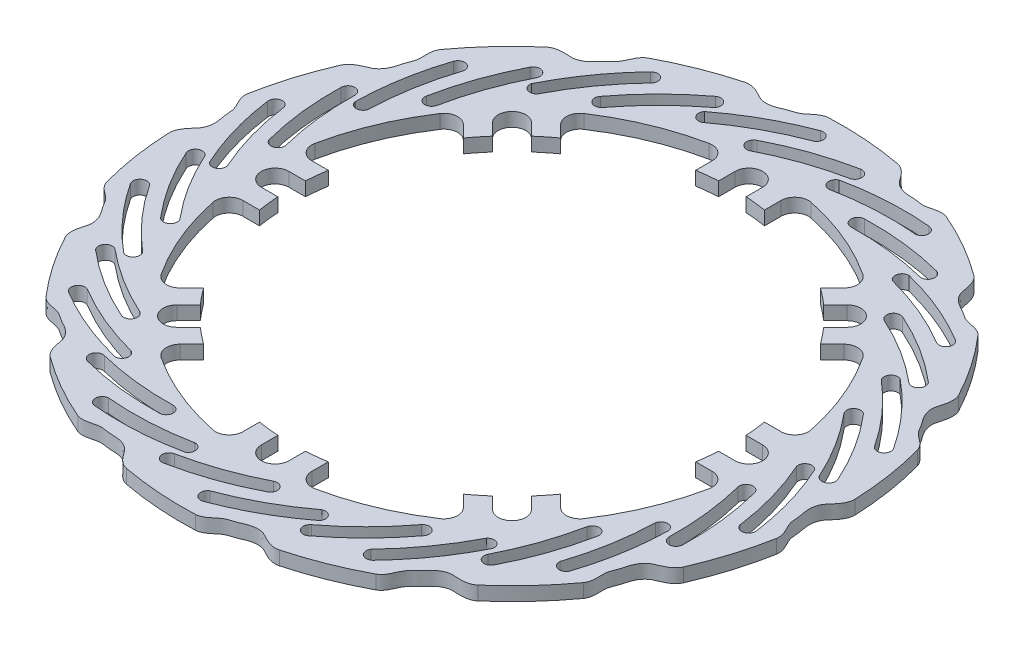
from build123d import *

# Parameters (mm, degrees)
DODANIE_WYCI_GNI_CIE1_DEPTH = 5


with BuildPart() as part:
    # Szkic1 → Dodanie-wyciągnięcie1 (new body)
    with BuildSketch(Plane.XZ):
        with BuildLine():
            ThreePointArc((31.315332852, 115.841917838), (44.179213836, 111.571488584), (56.479453956, 105.87762408))
            add(Edge.make_bspline(
                [(56.479453956, 105.87762408), (57.7973549, 105.079372549), (59.197175801, 102.852685767), (60.48538659, 99.334780786), (63.365232157, 97.088946445), (65.548394796, 94.026582105), (69.380131301, 91.841814605), (73.854427475, 92.533279482), (77.134407867, 91.946217157), (78.476064445, 90.782747861)],
                knots=[0, 0, 0, 0, 0.147553596, 0.283238405, 0.382647471, 0.524820265, 0.68196142, 0.812365732, 1, 1, 1, 1], degree=3))
            ThreePointArc((78.476064445, 90.782747861), (88.21315092, 81.353795269), (96.824809115, 70.886926438))
            add(Edge.make_bspline(
                [(96.824809115, 70.886926438), (97.665848478, 69.595910871), (97.960920344, 66.982375875), (97.595196392, 63.253919293), (99.215416591, 59.980974306), (99.853668074, 56.274640605), (102.358008279, 52.64370494), (106.689225217, 51.325368919), (109.389668596, 49.373313865), (110.09364903, 47.742941293)],
                knots=[0, 0, 0, 0, 0.147553596, 0.283238405, 0.382647471, 0.524820265, 0.68196142, 0.812365732, 1, 1, 1, 1], degree=3))
            ThreePointArc((110.09364903, 47.742941293), (114.775391602, 35.022985063), (117.992823351, 21.856203644))
            add(Edge.make_bspline(
                [(117.992823351, 21.856203644), (118.190422971, 20.328125506), (117.3223032, 17.845384955), (115.375080623, 14.644843325), (115.414770972, 10.993034587), (114.381697764, 7.376816369), (115.062626377, 3.018863882), (118.392913452, -0.048160431), (119.978963868, -2.978579732), (119.905836215, -4.752940328)],
                knots=[0, 0, 0, 0, 0.147553596, 0.283238405, 0.382647471, 0.524820265, 0.68196142, 0.812365732, 1, 1, 1, 1], degree=3))
            ThreePointArc((119.905836215, -4.752940328), (118.604958349, -18.244556864), (115.790911836, -31.503408331))
            add(Edge.make_bspline(
                [(115.790911836, -31.503408331), (115.305934686, -32.965894423), (113.446565044, -34.826103314), (110.303515154, -36.86482347), (108.754814493, -40.172210452), (106.255029413, -42.98207682), (104.977680171, -47.20390019), (106.647433182, -51.412151028), (106.804953908, -54.740529052), (105.969201989, -56.307443825)],
                knots=[0, 0, 0, 0, 0.147553596, 0.283238405, 0.382647471, 0.524820265, 0.68196142, 0.812365732, 1, 1, 1, 1], degree=3))
            ThreePointArc((105.969201989, -56.307443825), (98.943358501, -67.89854055), (90.655190149, -78.623383922))
            add(Edge.make_bspline(
                [(90.655190149, -78.623383922), (89.583691901, -79.730614661), (87.101343351, -80.599854708), (83.384985725, -81.07295986), (80.554633213, -83.380856531), (77.083249354, -84.827842555), (74.100616942, -88.077352909), (73.779120818, -92.593334589), (72.47691297, -95.660445229), (71.044067681, -96.709567508)],
                knots=[0, 0, 0, 0, 0.147553596, 0.283238405, 0.382647471, 0.524820265, 0.68196142, 0.812365732, 1, 1, 1, 1], degree=3))
            ThreePointArc((71.044067681, -96.709567508), (59.684813041, -104.104385559), (47.564096239, -110.171034075))
            add(Edge.make_bspline(
                [(47.564096239, -110.171034075), (46.118300263, -110.703708834), (43.504632379, -110.409816384), (39.951037223, -109.223602255), (36.399618888, -110.074901376), (32.644186396, -109.872413726), (28.547017745, -111.506005688), (26.29794873, -115.435272651), (23.793930565, -117.633637036), (22.047784471, -117.957175281)],
                knots=[0, 0, 0, 0, 0.147553596, 0.283238405, 0.382647471, 0.524820265, 0.68196142, 0.812365732, 1, 1, 1, 1], degree=3))
            ThreePointArc((22.047784471, -117.957175281), (8.604958371, -119.691080251), (-4.947650265, -119.897959771))
            add(Edge.make_bspline(
                [(-4.947650265, -119.897959771), (-6.481386346, -119.750575781), (-8.708704585, -118.351759838), (-11.395704168, -115.741170684), (-14.96478637, -114.967262022), (-18.260458033, -113.155405862), (-22.660668422, -112.84952651), (-26.391854628, -115.413839238), (-29.601731603, -116.308044362), (-31.315332852, -115.841917839)],
                knots=[0, 0, 0, 0, 0.147553596, 0.283238405, 0.382647471, 0.524820265, 0.68196142, 0.812365732, 1, 1, 1, 1], degree=3))
            ThreePointArc((-31.315332852, -115.841917839), (-44.179213836, -111.571488585), (-56.479453956, -105.877624081))
            add(Edge.make_bspline(
                [(-56.479453956, -105.877624081), (-57.7973549, -105.07937255), (-59.197175801, -102.852685768), (-60.48538659, -99.334780786), (-63.365232157, -97.088946445), (-65.548394798, -94.026582107), (-69.380131296, -91.841814599), (-73.854427495, -92.533279504), (-77.134407806, -91.946217086), (-78.476064446, -90.782747861)],
                knots=[0, 0, 0, 0, 0.147553596, 0.283238405, 0.382647471, 0.524820265, 0.68196142, 0.812365732, 1, 1, 1, 1], degree=3))
            ThreePointArc((-78.476064446, -90.782747861), (-88.213150921, -81.35379527), (-96.824809116, -70.886926439))
            add(Edge.make_bspline(
                [(-96.824809116, -70.886926439), (-97.665848477, -69.595910871), (-97.960920344, -66.982375875), (-97.595196392, -63.253919293), (-99.215416591, -59.980974306), (-99.853668074, -56.274640605), (-102.358008277, -52.64370494), (-106.689225223, -51.325368922), (-109.389668578, -49.373313857), (-110.093649031, -47.742941293)],
                knots=[0, 0, 0, 0, 0.147553596, 0.283238405, 0.382647471, 0.524820265, 0.68196142, 0.812365732, 1, 1, 1, 1], degree=3))
            ThreePointArc((-110.093649031, -47.742941293), (-114.775391602, -35.022985063), (-117.992823351, -21.856203644))
            add(Edge.make_bspline(
                [(-117.992823351, -21.856203644), (-118.190422971, -20.328125506), (-117.3223032, -17.845384955), (-115.375080623, -14.644843325), (-115.414770973, -10.993034587), (-114.381697763, -7.376816369), (-115.062626382, -3.018863882), (-118.392913433, 0.048160431), (-119.978963928, 2.978579735), (-119.905836214, 4.752940328)],
                knots=[0, 0, 0, 0, 0.147553596, 0.283238405, 0.382647471, 0.524820265, 0.68196142, 0.812365732, 1, 1, 1, 1], degree=3))
            ThreePointArc((-119.905836214, 4.752940328), (-118.604958349, 18.244556864), (-115.790911835, 31.503408331))
            add(Edge.make_bspline(
                [(-115.790911835, 31.503408331), (-115.305934685, 32.965894423), (-113.446565044, 34.826103314), (-110.303515154, 36.86482347), (-108.754814494, 40.172210452), (-106.255029411, 42.982076819), (-104.977680181, 47.203900195), (-106.647433147, 51.412151009), (-106.804954019, 54.740529112), (-105.969201988, 56.307443825)],
                knots=[0, 0, 0, 0, 0.147553596, 0.283238405, 0.382647471, 0.524820265, 0.68196142, 0.812365732, 1, 1, 1, 1], degree=3))
            ThreePointArc((-105.969201988, 56.307443825), (-98.9433585, 67.898540549), (-90.655190148, 78.623383921))
            add(Edge.make_bspline(
                [(-90.655190148, 78.623383921), (-89.5836919, 79.730614661), (-87.101343351, 80.599854708), (-83.384985724, 81.07295986), (-80.554633214, 83.380856532), (-77.083249352, 84.827842552), (-74.100616951, 88.077352921), (-73.779120787, 92.593334547), (-72.476913069, 95.660445365), (-71.04406768, 96.709567507)],
                knots=[0, 0, 0, 0, 0.147553596, 0.283238405, 0.382647471, 0.524820265, 0.68196142, 0.812365732, 1, 1, 1, 1], degree=3))
            ThreePointArc((-71.04406768, 96.709567507), (-59.68481304, 104.104385558), (-47.564096239, 110.171034074))
            add(Edge.make_bspline(
                [(-47.564096239, 110.171034074), (-46.118300263, 110.703708834), (-43.504632378, 110.409816384), (-39.951037223, 109.223602255), (-36.399618888, 110.074901376), (-32.644186395, 109.872413723), (-28.547017748, 111.5060057), (-26.297948722, 115.435272608), (-23.79393059, 117.633637172), (-22.047784471, 117.957175279)],
                knots=[0, 0, 0, 0, 0.147553596, 0.283238405, 0.382647471, 0.524820265, 0.68196142, 0.812365732, 1, 1, 1, 1], degree=3))
            ThreePointArc((-22.047784471, 117.957175279), (-8.604958371, 119.69108025), (4.947650265, 119.897959769))
            add(Edge.make_bspline(
                [(4.947650265, 119.897959769), (6.481386346, 119.750575781), (8.708704586, 118.351759838), (11.395704168, 115.741170684), (14.964786371, 114.967262023), (18.260458032, 113.155405859), (22.660668426, 112.849526523), (26.391854615, 115.413839193), (29.601731642, 116.308044507), (31.315332852, 115.841917838)],
                knots=[0, 0, 0, 0, 0.147553596, 0.283238405, 0.382647471, 0.524820265, 0.68196142, 0.812365732, 1, 1, 1, 1], degree=3))
        make_face()
        with BuildLine():
            Line((-79.219883867, 12.499999999), (-85.221769519, 12.499999999))
            ThreePointArc((-85.221769519, 12.499999999), (-89.096607298, 14.339994907), (-90.119572365, 18.505747126))
            ThreePointArc((-90.119572365, 18.505747126), (-84.996916991, 35.206875777), (-76.809700021, 50.638621452))
            ThreePointArc((-76.809700021, 50.638621452), (-73.140722843, 52.860907559), (-69.099725896, 51.422056366))
            Line((-69.099725896, 51.422056366), (-64.855751852, 47.178082322))
            ThreePointArc((-64.855751852, 47.178082322), (-62.564723559, 50.176641636), (-60.135180548, 53.064112735))
            Line((-60.135180548, 53.064112735), (-64.377821235, 57.306753422))
            ThreePointArc((-64.377821235, 57.306753422), (-64.377821235, 64.377821234), (-57.306753423, 64.377821234))
            Line((-57.306753423, 64.377821234), (-53.064112736, 60.135180547))
            ThreePointArc((-53.064112736, 60.135180547), (-50.176641636, 62.564723559), (-47.178082323, 64.855751852))
            Line((-47.178082323, 64.855751852), (-51.422056367, 69.099725896))
            ThreePointArc((-51.422056367, 69.099725896), (-52.86090756, 73.140722842), (-50.638621453, 76.80970002))
            ThreePointArc((-50.638621453, 76.80970002), (-35.206875777, 84.99691699), (-18.505747126, 90.119572364))
            ThreePointArc((-18.505747126, 90.119572364), (-14.339994907, 89.096607298), (-12.5, 85.221769519))
            Line((-12.5, 85.221769519), (-12.5, 79.219883867))
            ThreePointArc((-12.5, 79.219883867), (-8.759696733, 79.72018385), (-5, 80.043987906))
            Line((-5, 80.043987906), (-5, 86.043987906))
            ThreePointArc((-5, 86.043987906), (0, 91.043987906), (5, 86.043987906))
            Line((5, 86.043987906), (5, 80.043987906))
            ThreePointArc((5, 80.043987906), (8.759696734, 79.72018385), (12.5, 79.219883867))
            Line((12.5, 79.219883867), (12.5, 85.221769519))
            ThreePointArc((12.5, 85.221769519), (14.339994908, 89.096607298), (18.505747127, 90.119572364))
            ThreePointArc((18.505747127, 90.119572364), (35.206875778, 84.99691699), (50.638621453, 76.80970002))
            ThreePointArc((50.638621453, 76.80970002), (52.86090756, 73.140722842), (51.422056367, 69.099725896))
            Line((51.422056367, 69.099725896), (47.178082323, 64.855751852))
            ThreePointArc((47.178082323, 64.855751852), (50.176641637, 62.564723559), (53.064112736, 60.135180547))
            Line((53.064112736, 60.135180547), (57.306753423, 64.377821234))
            ThreePointArc((57.306753423, 64.377821234), (64.377821235, 64.377821234), (64.377821235, 57.306753422))
            Line((64.377821235, 57.306753422), (60.135180548, 53.064112735))
            ThreePointArc((60.135180548, 53.064112735), (62.56472356, 50.176641636), (64.855751853, 47.178082322))
            Line((64.855751853, 47.178082322), (69.099725897, 51.422056366))
            ThreePointArc((69.099725897, 51.422056366), (73.140722843, 52.860907559), (76.809700021, 50.638621452))
            ThreePointArc((76.809700021, 50.638621452), (84.996916991, 35.206875777), (90.119572365, 18.505747126))
            ThreePointArc((90.119572365, 18.505747126), (89.096607299, 14.339994907), (85.22176952, 12.499999999))
            Line((85.22176952, 12.499999999), (79.219883868, 12.499999999))
            ThreePointArc((79.219883868, 12.499999999), (79.720183851, 8.759696733), (80.043987907, 4.999999999))
            Line((80.043987907, 4.999999999), (86.043987907, 4.999999999))
            ThreePointArc((86.043987907, 4.999999999), (91.043987907, -1e-09), (86.043987907, -5.000000001))
            Line((86.043987907, -5.000000001), (80.043987907, -5.000000001))
            ThreePointArc((80.043987907, -5.000000001), (79.720183851, -8.759696734), (79.219883868, -12.500000001))
            Line((79.219883868, -12.500000001), (85.22176952, -12.500000001))
            ThreePointArc((85.22176952, -12.500000001), (89.096607299, -14.339994908), (90.119572365, -18.505747127))
            ThreePointArc((90.119572365, -18.505747127), (84.996916991, -35.206875778), (76.809700021, -50.638621454))
            ThreePointArc((76.809700021, -50.638621454), (73.140722843, -52.860907561), (69.099725897, -51.422056368))
            Line((69.099725897, -51.422056368), (64.855751853, -47.178082324))
            ThreePointArc((64.855751853, -47.178082324), (62.56472356, -50.176641637), (60.135180548, -53.064112737))
            Line((60.135180548, -53.064112737), (64.377821235, -57.306753424))
            ThreePointArc((64.377821235, -57.306753424), (64.377821235, -64.377821236), (57.306753423, -64.377821236))
            Line((57.306753423, -64.377821236), (53.064112736, -60.135180549))
            ThreePointArc((53.064112736, -60.135180549), (50.176641637, -62.56472356), (47.178082323, -64.855751853))
            Line((47.178082323, -64.855751853), (51.422056367, -69.099725897))
            ThreePointArc((51.422056367, -69.099725897), (52.86090756, -73.140722844), (50.638621453, -76.809700022))
            ThreePointArc((50.638621453, -76.809700022), (35.206875778, -84.996916992), (18.505747127, -90.119572366))
            ThreePointArc((18.505747127, -90.119572366), (14.339994908, -89.096607299), (12.5, -85.22176952))
            Line((12.5, -85.22176952), (12.5, -79.219883868))
            ThreePointArc((12.5, -79.219883868), (8.759696734, -79.720183851), (5, -80.043987907))
            Line((5, -80.043987907), (5, -86.043987907))
            ThreePointArc((5, -86.043987907), (0, -91.043987907), (-5, -86.043987907))
            Line((-5, -86.043987907), (-5, -80.043987907))
            ThreePointArc((-5, -80.043987907), (-8.759696733, -79.720183851), (-12.5, -79.219883868))
            Line((-12.5, -79.219883868), (-12.5, -85.22176952))
            ThreePointArc((-12.5, -85.22176952), (-14.339994907, -89.096607299), (-18.505747126, -90.119572366))
            ThreePointArc((-18.505747126, -90.119572366), (-35.206875777, -84.996916992), (-50.638621453, -76.809700022))
            ThreePointArc((-50.638621453, -76.809700022), (-52.86090756, -73.140722844), (-51.422056367, -69.099725897))
            Line((-51.422056367, -69.099725897), (-47.178082323, -64.855751853))
            ThreePointArc((-47.178082323, -64.855751853), (-50.176641636, -62.56472356), (-53.064112736, -60.135180549))
            Line((-53.064112736, -60.135180549), (-57.306753423, -64.377821236))
            ThreePointArc((-57.306753423, -64.377821236), (-64.377821235, -64.377821236), (-64.377821235, -57.306753424))
            Line((-64.377821235, -57.306753424), (-60.135180548, -53.064112737))
            ThreePointArc((-60.135180548, -53.064112737), (-62.564723559, -50.176641637), (-64.855751852, -47.178082324))
            Line((-64.855751852, -47.178082324), (-69.099725896, -51.422056368))
            ThreePointArc((-69.099725896, -51.422056368), (-73.140722843, -52.860907561), (-76.809700021, -50.638621454))
            ThreePointArc((-76.809700021, -50.638621454), (-84.996916991, -35.206875778), (-90.119572365, -18.505747127))
            ThreePointArc((-90.119572365, -18.505747127), (-89.096607298, -14.339994908), (-85.221769519, -12.500000001))
            Line((-85.221769519, -12.500000001), (-79.219883867, -12.500000001))
            ThreePointArc((-79.219883867, -12.500000001), (-79.72018385, -8.759696734), (-80.043987906, -5.000000001))
            Line((-80.043987906, -5.000000001), (-86.043987906, -5.000000001))
            ThreePointArc((-86.043987906, -5.000000001), (-91.043987906, -1e-09), (-86.043987906, 4.999999999))
            Line((-86.043987906, 4.999999999), (-80.043987906, 4.999999999))
            ThreePointArc((-80.043987906, 4.999999999), (-79.72018385, 8.759696733), (-79.219883867, 12.499999999))
        make_face(mode=Mode.SUBTRACT)
        with BuildLine():
            ThreePointArc((2.268312667, 114.334257918), (16.405394511, 107.826943281), (29.410258709, 99.278508685))
            ThreePointArc((29.410258709, 99.278508685), (29.416149704, 96.178074413), (26.400917875, 95.456198803))
            ThreePointArc((26.400917875, 95.456198803), (13.759854388, 103.608740692), (0.080835869, 109.865327437))
            ThreePointArc((0.080835869, 109.865327437), (-0.849204784, 113.090403236), (2.268312667, 114.334257918))
        make_face(mode=Mode.SUBTRACT)
        with BuildLine():
            ThreePointArc((-17.021818385, 109.530618868), (-2.743365473, 105.63635259), (10.842358325, 99.765438156))
            ThreePointArc((10.842358325, 99.765438156), (12.010071147, 96.428306638), (8.67293963, 95.260593816))
            ThreePointArc((8.67293963, 95.260593816), (-4.35084411, 100.849193335), (-18.00964822, 104.629200974))
            ThreePointArc((-18.00964822, 104.629200974), (-19.958040423, 107.572131537), (-17.021818385, 109.530618868))
        make_face(mode=Mode.SUBTRACT)
        with BuildLine():
            ThreePointArc((51.651454431, 102.027422937), (61.565107048, 90.030685105), (69.573058056, 76.68621256))
            ThreePointArc((69.573058056, 76.68621256), (68.233137644, 73.890261797), (65.203297548, 74.548134406))
            ThreePointArc((65.203297548, 74.548134406), (57.351348247, 87.378072735), (47.741609669, 98.950166313))
            ThreePointArc((47.741609669, 98.950166313), (48.302979942, 102.259388721), (51.651454431, 102.027422937))
        make_face(mode=Mode.SUBTRACT)
        with BuildLine():
            ThreePointArc((32.187426022, 106.06916789), (43.362208764, 96.365366671), (53.055228647, 85.1812309))
            ThreePointArc((53.055228647, 85.1812309), (52.659374446, 81.667927689), (49.146071235, 82.063781891))
            ThreePointArc((49.146071235, 82.063781891), (39.836849999, 92.749744058), (29.170776571, 102.081746261))
            ThreePointArc((29.170776571, 102.081746261), (28.692225571, 105.578610773), (32.187426022, 106.06916789))
        make_face(mode=Mode.SUBTRACT)
        with BuildLine():
            ThreePointArc((90.80439218, 69.51280556), (94.531095088, 54.40274559), (95.956059997, 38.905271543))
            ThreePointArc((95.956059997, 38.905271543), (93.535715849, 36.967576627), (91.091364475, 38.874897717))
            ThreePointArc((91.091364475, 38.874897717), (89.583704218, 53.84110585), (85.946572162, 68.436711207))
            ThreePointArc((85.946572162, 68.436711207), (87.888167093, 71.174648141), (90.80439218, 69.51280556))
        make_face(mode=Mode.SUBTRACT)
        with BuildLine():
            ThreePointArc((75.021555953, 81.599417358), (80.879365753, 68.00803804), (84.759860256, 53.725836185))
            ThreePointArc((84.759860256, 53.725836185), (82.878842811, 50.73221407), (79.885220695, 52.613231515))
            ThreePointArc((79.885220695, 52.613231515), (76.134367399, 66.28007047), (70.573571307, 79.31574975))
            ThreePointArc((70.573571307, 79.31574975), (71.659644404, 82.673951309), (75.021555953, 81.599417358))
        make_face(mode=Mode.SUBTRACT)
        with BuildLine():
            ThreePointArc((111.972406416, 23.230324522), (108.774040398, 7.999675105), (103.333787432, -6.581335645))
            ThreePointArc((103.333787432, -6.581335645), (100.31239839, -7.276990471), (98.937669506, -4.497989234))
            ThreePointArc((98.937669506, -4.497989234), (104.072908896, 9.640247635), (107.128761972, 24.368526126))
            ThreePointArc((107.128761972, 24.368526126), (110.066024873, 25.992895596), (111.972406416, 23.230324522))
        make_face(mode=Mode.SUBTRACT)
        with BuildLine():
            ThreePointArc((102.996746648, 40.967901467), (102.377372434, 26.180883411), (99.67676203, 11.62938071))
            ThreePointArc((99.67676203, 11.62938071), (96.683139914, 9.748363264), (94.802122469, 12.74198538))
            ThreePointArc((94.802122469, 12.74198538), (97.352539608, 26.682816054), (97.998404717, 40.840296258))
            ThreePointArc((97.998404717, 40.840296258), (100.433991814, 43.394701858), (102.996746648, 40.967901467))
        make_face(mode=Mode.SUBTRACT)
        with BuildLine():
            ThreePointArc((110.96291231, -27.653207188), (101.472952981, -39.987829144), (90.244990961, -50.764428594))
            ThreePointArc((90.244990961, -50.764428594), (87.220980179, -50.080260359), (87.188155701, -46.979994253))
            ThreePointArc((87.188155701, -46.979994253), (97.949197597, -36.469979855), (107.092786626, -24.526144415))
            ThreePointArc((107.092786626, -24.526144415), (110.443956556, -24.337068703), (110.96291231, -27.653207188))
        make_face(mode=Mode.SUBTRACT)
        with BuildLine():
            ThreePointArc((110.572168498, -7.777809748), (103.598284928, -20.831716265), (94.851458628, -32.77041624))
            ThreePointArc((94.851458628, -32.77041624), (91.338155417, -33.166270442), (90.942301216, -29.652967231))
            ThreePointArc((90.942301216, -29.652967231), (99.288847398, -18.199297325), (106.013452201, -5.724078782))
            ThreePointArc((106.013452201, -5.724078782), (109.316155404, -4.479400497), (110.572168498, -7.777809748))
        make_face(mode=Mode.SUBTRACT)
        with BuildLine():
            ThreePointArc((87.97585255, -73.05968207), (74.073902742, -80.055253412), (59.282067247, -84.893003875))
            ThreePointArc((59.282067247, -84.893003875), (56.854377149, -82.96452049), (58.169958366, -80.157035238))
            ThreePointArc((58.169958366, -80.157035238), (72.425446446, -75.35688056), (85.845771482, -68.563111262))
            ThreePointArc((85.845771482, -68.563111262), (88.947108137, -69.846778071), (87.97585255, -73.05968207))
        make_face(mode=Mode.SUBTRACT)
        with BuildLine():
            ThreePointArc((96.247416297, -54.983030353), (84.300286543, -63.718339051), (71.239660568, -70.679630351))
            ThreePointArc((71.239660568, -70.679630351), (67.902529051, -69.511917529), (69.070241873, -66.174786011))
            ThreePointArc((69.070241873, -66.174786011), (81.559781263, -59.47681667), (93.031235307, -51.154729817))
            ThreePointArc((93.031235307, -51.154729817), (96.546913741, -51.466302647), (96.247416297, -54.983030353))
        make_face(mode=Mode.SUBTRACT)
        with BuildLine():
            ThreePointArc((47.564096239, -103.9957909), (32.003607608, -104.266752929), (16.577603069, -102.207478594))
            ThreePointArc((16.577603069, -102.207478594), (15.227067451, -99.416639845), (17.630487369, -97.457992333))
            ThreePointArc((17.630487369, -97.457992333), (32.556947386, -99.318426878), (47.595948466, -99.020313051))
            ThreePointArc((47.595948466, -99.020313051), (49.833194087, -101.522476427), (47.564096239, -103.9957909))
        make_face(mode=Mode.SUBTRACT)
        with BuildLine():
            ThreePointArc((62.859682902, -91.298187475), (48.305582533, -93.984763333), (33.517974036, -94.589876842))
            ThreePointArc((33.517974036, -94.589876842), (31.017974036, -92.089876842), (33.517974036, -89.589876842))
            ThreePointArc((33.517974036, -89.589876842), (47.676800183, -88.974223037), (61.623041307, -86.453559241))
            ThreePointArc((61.623041307, -86.453559241), (64.655371741, -88.259672365), (62.859682902, -91.298187475))
        make_face(mode=Mode.SUBTRACT)
        with BuildLine():
            ThreePointArc((-2.268312667, -114.334257918), (-16.405394511, -107.826943281), (-29.410258709, -99.278508685))
            ThreePointArc((-29.410258709, -99.278508685), (-29.416149704, -96.178074413), (-26.400917875, -95.456198803))
            ThreePointArc((-26.400917875, -95.456198803), (-13.759854388, -103.608740692), (-0.080835869, -109.865327437))
            ThreePointArc((-0.080835869, -109.865327437), (0.849204784, -113.090403236), (-2.268312667, -114.334257918))
        make_face(mode=Mode.SUBTRACT)
        with BuildLine():
            ThreePointArc((17.021818385, -109.530618868), (2.743365473, -105.63635259), (-10.842358325, -99.765438156))
            ThreePointArc((-10.842358325, -99.765438156), (-12.010071147, -96.428306638), (-8.67293963, -95.260593816))
            ThreePointArc((-8.67293963, -95.260593816), (4.35084411, -100.849193335), (18.00964822, -104.629200974))
            ThreePointArc((18.00964822, -104.629200974), (19.958040423, -107.572131537), (17.021818385, -109.530618868))
        make_face(mode=Mode.SUBTRACT)
        with BuildLine():
            ThreePointArc((-51.651454431, -102.027422937), (-61.565107048, -90.030685105), (-69.573058056, -76.68621256))
            ThreePointArc((-69.573058056, -76.68621256), (-68.233137644, -73.890261797), (-65.203297548, -74.548134406))
            ThreePointArc((-65.203297548, -74.548134406), (-57.351348247, -87.378072735), (-47.741609669, -98.950166313))
            ThreePointArc((-47.741609669, -98.950166313), (-48.302979942, -102.259388721), (-51.651454431, -102.027422937))
        make_face(mode=Mode.SUBTRACT)
        with BuildLine():
            ThreePointArc((-32.187426022, -106.06916789), (-43.362208764, -96.365366671), (-53.055228647, -85.1812309))
            ThreePointArc((-53.055228647, -85.1812309), (-52.659374446, -81.667927689), (-49.146071235, -82.063781891))
            ThreePointArc((-49.146071235, -82.063781891), (-39.836849999, -92.749744058), (-29.170776571, -102.081746261))
            ThreePointArc((-29.170776571, -102.081746261), (-28.692225571, -105.578610773), (-32.187426022, -106.06916789))
        make_face(mode=Mode.SUBTRACT)
        with BuildLine():
            ThreePointArc((-90.80439218, -69.51280556), (-94.531095088, -54.40274559), (-95.956059997, -38.905271543))
            ThreePointArc((-95.956059997, -38.905271543), (-93.535715849, -36.967576627), (-91.091364475, -38.874897717))
            ThreePointArc((-91.091364475, -38.874897717), (-89.583704218, -53.84110585), (-85.946572162, -68.436711207))
            ThreePointArc((-85.946572162, -68.436711207), (-87.888167093, -71.174648141), (-90.80439218, -69.51280556))
        make_face(mode=Mode.SUBTRACT)
        with BuildLine():
            ThreePointArc((-75.021555953, -81.599417358), (-80.879365753, -68.00803804), (-84.759860256, -53.725836185))
            ThreePointArc((-84.759860256, -53.725836185), (-82.878842811, -50.73221407), (-79.885220695, -52.613231515))
            ThreePointArc((-79.885220695, -52.613231515), (-76.134367399, -66.28007047), (-70.573571307, -79.31574975))
            ThreePointArc((-70.573571307, -79.31574975), (-71.659644404, -82.673951309), (-75.021555953, -81.599417358))
        make_face(mode=Mode.SUBTRACT)
        with BuildLine():
            ThreePointArc((-111.972406416, -23.230324522), (-108.774040398, -7.999675105), (-103.333787432, 6.581335645))
            ThreePointArc((-103.333787432, 6.581335645), (-100.31239839, 7.276990471), (-98.937669506, 4.497989234))
            ThreePointArc((-98.937669506, 4.497989234), (-104.072908896, -9.640247635), (-107.128761972, -24.368526126))
            ThreePointArc((-107.128761972, -24.368526126), (-110.066024873, -25.992895596), (-111.972406416, -23.230324522))
        make_face(mode=Mode.SUBTRACT)
        with BuildLine():
            ThreePointArc((-102.996746648, -40.967901467), (-102.377372434, -26.180883411), (-99.67676203, -11.62938071))
            ThreePointArc((-99.67676203, -11.62938071), (-96.683139914, -9.748363264), (-94.802122469, -12.74198538))
            ThreePointArc((-94.802122469, -12.74198538), (-97.352539608, -26.682816054), (-97.998404717, -40.840296258))
            ThreePointArc((-97.998404717, -40.840296258), (-100.433991814, -43.394701858), (-102.996746648, -40.967901467))
        make_face(mode=Mode.SUBTRACT)
        with BuildLine():
            ThreePointArc((-110.96291231, 27.653207188), (-101.472952981, 39.987829144), (-90.244990961, 50.764428594))
            ThreePointArc((-90.244990961, 50.764428594), (-87.220980179, 50.080260359), (-87.188155701, 46.979994253))
            ThreePointArc((-87.188155701, 46.979994253), (-97.949197597, 36.469979855), (-107.092786626, 24.526144415))
            ThreePointArc((-107.092786626, 24.526144415), (-110.443956556, 24.337068703), (-110.96291231, 27.653207188))
        make_face(mode=Mode.SUBTRACT)
        with BuildLine():
            ThreePointArc((-110.572168498, 7.777809748), (-103.598284928, 20.831716265), (-94.851458628, 32.77041624))
            ThreePointArc((-94.851458628, 32.77041624), (-91.338155417, 33.166270442), (-90.942301216, 29.652967231))
            ThreePointArc((-90.942301216, 29.652967231), (-99.288847398, 18.199297325), (-106.013452201, 5.724078782))
            ThreePointArc((-106.013452201, 5.724078782), (-109.316155404, 4.479400497), (-110.572168498, 7.777809748))
        make_face(mode=Mode.SUBTRACT)
        with BuildLine():
            ThreePointArc((-61.623041307, 86.453559241), (-64.655371741, 88.259672365), (-62.859682902, 91.298187475))
            ThreePointArc((-62.859682902, 91.298187475), (-48.305582533, 93.984763333), (-33.517974036, 94.589876842))
            ThreePointArc((-33.517974036, 94.589876842), (-31.017974036, 92.089876842), (-33.517974036, 89.589876842))
            ThreePointArc((-33.517974036, 89.589876842), (-47.676800183, 88.974223037), (-61.623041307, 86.453559241))
        make_face(mode=Mode.SUBTRACT)
        with BuildLine():
            ThreePointArc((-87.97585255, 73.05968207), (-74.073902742, 80.055253412), (-59.282067247, 84.893003875))
            ThreePointArc((-59.282067247, 84.893003875), (-56.854377149, 82.96452049), (-58.169958366, 80.157035238))
            ThreePointArc((-58.169958366, 80.157035238), (-72.425446446, 75.35688056), (-85.845771482, 68.563111262))
            ThreePointArc((-85.845771482, 68.563111262), (-88.947108137, 69.846778071), (-87.97585255, 73.05968207))
        make_face(mode=Mode.SUBTRACT)
        with BuildLine():
            ThreePointArc((-47.595948466, 99.020313051), (-49.833194087, 101.522476427), (-47.564096239, 103.9957909))
            ThreePointArc((-47.564096239, 103.9957909), (-32.003607608, 104.266752929), (-16.577603069, 102.207478594))
            ThreePointArc((-16.577603069, 102.207478594), (-15.227067451, 99.416639845), (-17.630487369, 97.457992333))
            ThreePointArc((-17.630487369, 97.457992333), (-32.556947386, 99.318426878), (-47.595948466, 99.020313051))
        make_face(mode=Mode.SUBTRACT)
        with BuildLine():
            ThreePointArc((-96.247416297, 54.983030353), (-84.300286543, 63.718339051), (-71.239660568, 70.679630351))
            ThreePointArc((-71.239660568, 70.679630351), (-67.902529051, 69.511917529), (-69.070241873, 66.174786011))
            ThreePointArc((-69.070241873, 66.174786011), (-81.559781263, 59.47681667), (-93.031235307, 51.154729817))
            ThreePointArc((-93.031235307, 51.154729817), (-96.546913741, 51.466302647), (-96.247416297, 54.983030353))
        make_face(mode=Mode.SUBTRACT)
    extrude(amount=-DODANIE_WYCI_GNI_CIE1_DEPTH)


solid = part.part
